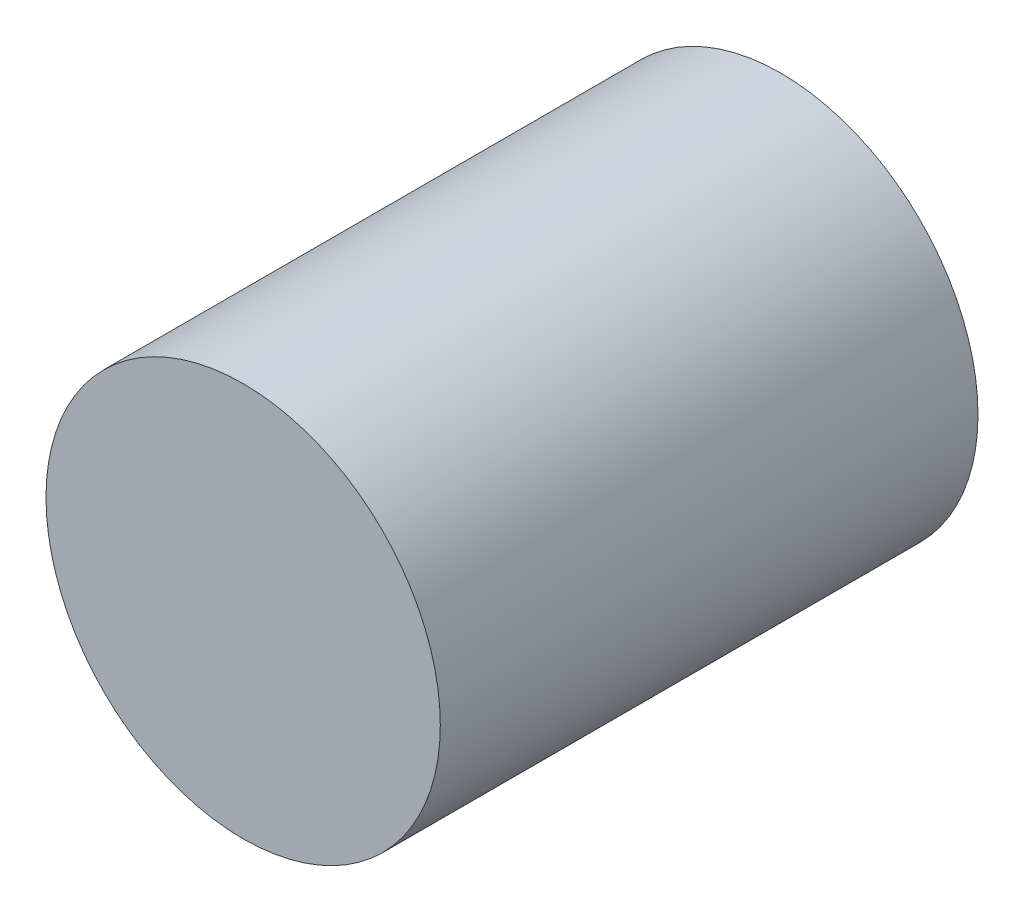
from build123d import *

# Parameters (mm, degrees)
SKETCH1_R                = 27.5
BOSS_EXTRUDE1_DEPTH      = 44
BOSS_EXTRUDE1_DEPTH_BACK = 31
CUT_EXTRUDE1_DEPTH       = 10


with BuildPart() as part:
    # Sketch1 → Boss-Extrude1 (new body, two sides)
    with BuildSketch(Plane.XY) as boss_extrude1_sk:
        with Locations((0, -206.1)):
            Circle(SKETCH1_R)
    extrude(amount=BOSS_EXTRUDE1_DEPTH)
    extrude(boss_extrude1_sk.sketch, amount=-BOSS_EXTRUDE1_DEPTH_BACK)

    # Sketch2 → Cut-Extrude1 (cut)
    with BuildSketch(Plane(origin=(0, 0, -31), x_dir=(-1, 0, 0), z_dir=(0, 0, -1))):
        Polygon((22.5, -206.1), (5.5, -191.1), (5.5, -201.1), (-19.5, -201.1), (-19.5, -211.1), (5.5, -211.1), (5.5, -221.1), align=None)
    extrude(amount=-CUT_EXTRUDE1_DEPTH, mode=Mode.SUBTRACT)


solid = part.part
